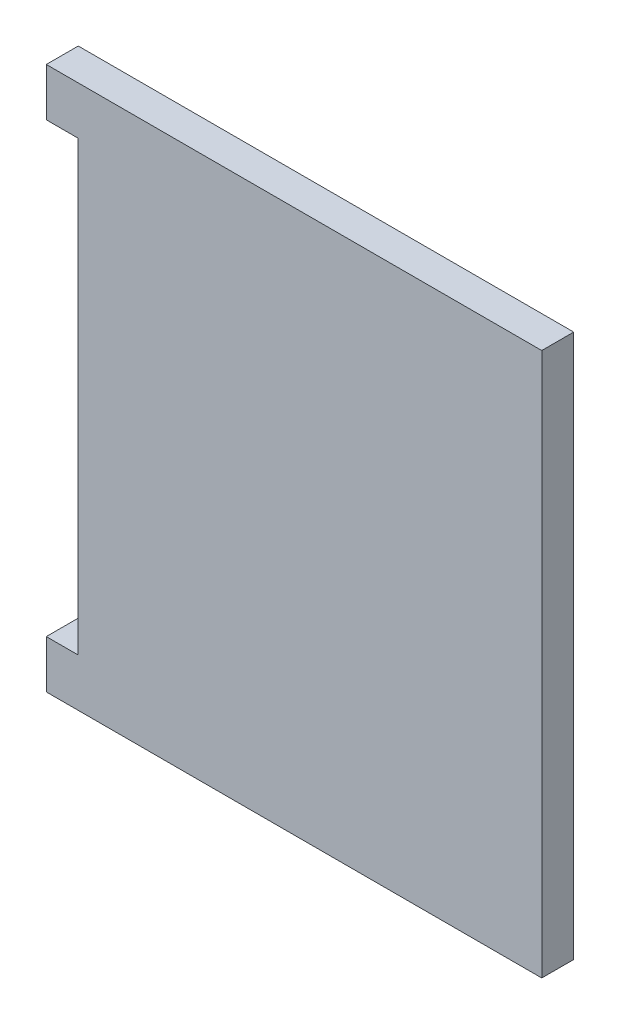
from build123d import *

# Parameters (mm, degrees)
SKETCH1_W           = 196.85
SKETCH1_H           = 215.9
BOSS_EXTRUDE1_DEPTH = 12.7
SKETCH2_W           = 12.7
SKETCH2_H           = 177.8
CUT_EXTRUDE1_DEPTH  = 13.7


with BuildPart() as part:
    # Sketch1 → Boss-Extrude1 (new body)
    with BuildSketch(Plane.XY):
        with Locations((98.425, -107.95)):
            Rectangle(SKETCH1_W, SKETCH1_H)
    extrude(amount=BOSS_EXTRUDE1_DEPTH)

    # Sketch2 → Cut-Extrude1 (cut, through all)
    with BuildSketch(Plane(origin=(0, 0, 0), x_dir=(-1, 0, 0), z_dir=(0, 0, -1))):
        with Locations((-6.35, -107.95)):
            Rectangle(SKETCH2_W, SKETCH2_H)
    extrude(amount=-CUT_EXTRUDE1_DEPTH, mode=Mode.SUBTRACT)


solid = part.part
